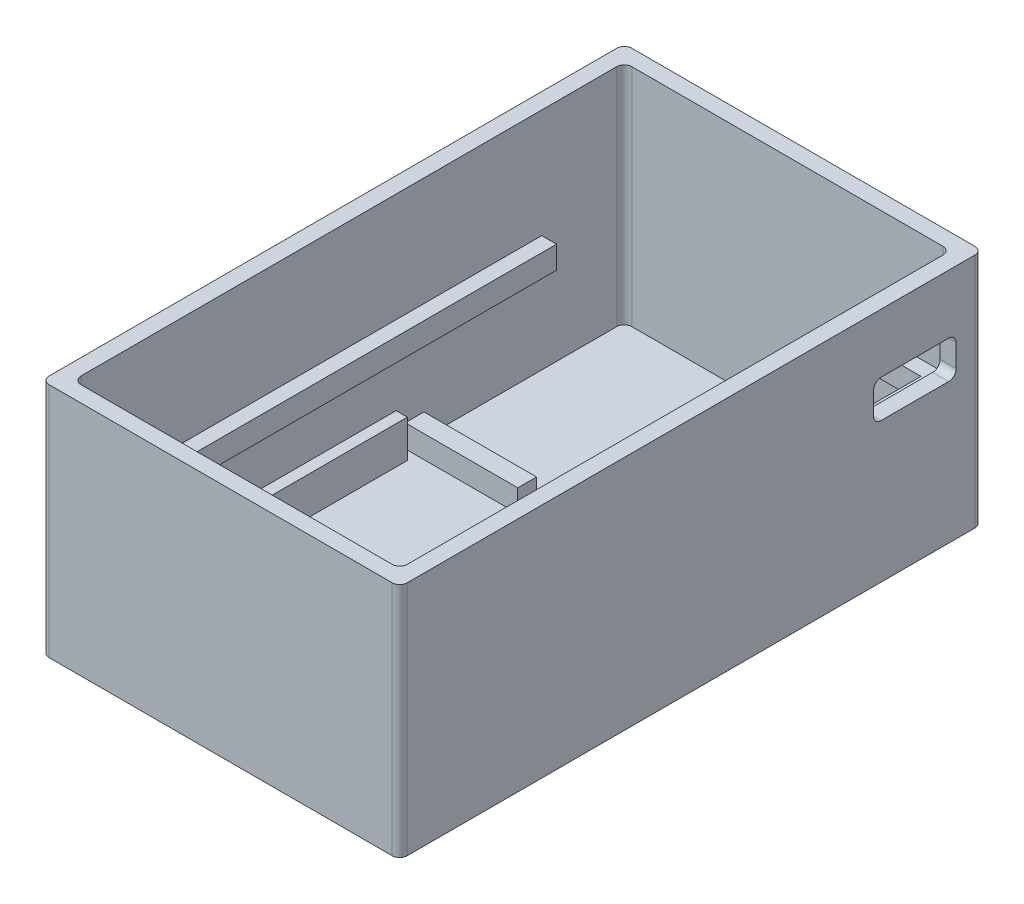
from build123d import *

# Parameters (mm, degrees)
PCB_DIMENSIONS_W    = 47.716732244
PCB_DIMENSIONS_H    = 77.636732244
BOSS_EXTRUDE3_DEPTH = 1.5
SKETCH5_W           = 47.716732244
SKETCH5_H           = 77.636732244
SKETCH5_W_2         = 43.474091557
SKETCH5_H_2         = 73.394091557
BOSS_EXTRUDE5_DEPTH = 30
FILLET1_R           = 1
SKETCH9_W           = 1.93805105
SKETCH9_H           = 42
SKETCH9_W_2         = 1.938051049
BOSS_EXTRUDE6_DEPTH = 5
SKETCH14_W          = 15
SKETCH14_H          = 2.5
BOSS_EXTRUDE7_DEPTH = 3
SKETCH15_W          = 75.636732244
SKETCH15_H          = 3
BOSS_EXTRUDE8_DEPTH = 46
SKETCH17_W          = 39.522771214
SKETCH17_H          = 62.982276128
CUT_EXTRUDE1_DEPTH  = 3
CUT_EXTRUDE2_DEPTH  = 3
SKETCH19_W          = 11
SKETCH19_H          = 5
CUT_EXTRUDE3_DEPTH  = 10
FILLET2_R           = 1
SCALE1_SCALE        = 0.99


with BuildPart() as part:
    # PCB Dimensions → Boss-Extrude3 (new body)
    with BuildSketch(Plane(origin=(0, 0, 0), x_dir=(1, 0, 0), z_dir=(0, 1, 0))):
        with Locations((20.322832216, -35.282832216)):
            Rectangle(PCB_DIMENSIONS_W, PCB_DIMENSIONS_H)
    extrude(amount=BOSS_EXTRUDE3_DEPTH)

    # Sketch5 → Boss-Extrude5 (add)
    with BuildSketch(Plane(origin=(0, 1.5, 0), x_dir=(1, 0, 0), z_dir=(0, 1, 0))):
        with Locations((20.322832216, -35.282832216)):
            Rectangle(SKETCH5_W, SKETCH5_H)
        with Locations((20.322832217, -35.282832217)):
            Rectangle(SKETCH5_W_2, SKETCH5_H_2, mode=Mode.SUBTRACT)
    extrude(amount=BOSS_EXTRUDE5_DEPTH)

    # Fillet1
    fillet1_edges = [part.edges().sort_by_distance(p)[0] for p in [
        (42.059877995, 16.5, -1.414213562),
        (-1.414213562, 16.5, -1.414213562),
        (-1.414213562, 16.5, 71.979877995),
        (42.059877995, 16.5, 71.979877995),
        (44.181198338, 15.75, 74.101198338),
        (-3.535533906, 15.75, 74.101198338),
        (-3.535533906, 15.75, -3.535533906),
        (44.181198338, 15.75, -3.535533906),
    ]]
    fillet(fillet1_edges, radius=FILLET1_R)

    # Sketch9 → Boss-Extrude6 (add)
    with BuildSketch(Plane(origin=(0, 1.5, 0), x_dir=(1, 0, 0), z_dir=(0, 1, 0))):
        with Locations((-0.88911969, -49.979881394)):
            Rectangle(SKETCH9_W, SKETCH9_H)
        with Locations((41.534784122, -49.979881394)):
            Rectangle(SKETCH9_W_2, SKETCH9_H)
    extrude(amount=BOSS_EXTRUDE6_DEPTH)

    # Sketch14 → Boss-Extrude7 (add)
    with BuildSketch(Plane(origin=(0, 1.5, 0), x_dir=(1, 0, 0), z_dir=(0, 1, 0))):
        with Locations((6.085786438, -26.529881394)):
            Rectangle(SKETCH14_W, SKETCH14_H)
        with Locations((34.559877995, -26.529881394)):
            Rectangle(SKETCH14_W, SKETCH14_H)
    extrude(amount=BOSS_EXTRUDE7_DEPTH)

    # Sketch15 → Boss-Extrude8 (add)
    with BuildSketch(Plane(origin=(44.181198338, 0, 0), x_dir=(0, 0, -1), z_dir=(1, 0, 0))):
        with Locations((-35.282832216, 15.5)):
            Rectangle(SKETCH15_W, SKETCH15_H)
    extrude(amount=-BOSS_EXTRUDE8_DEPTH)

    # Sketch17 → Cut-Extrude1 (cut)
    with BuildSketch(Plane(origin=(0, 17, 0), x_dir=(1, 0, 0), z_dir=(0, 1, 0))):
        with Locations((20.322832216, -32.052584673)):
            Rectangle(SKETCH17_W, SKETCH17_H)
    extrude(amount=-CUT_EXTRUDE1_DEPTH, mode=Mode.SUBTRACT)

    # Sketch18 → Cut-Extrude2 (cut)
    with BuildSketch(Plane(origin=(0, 17, 0), x_dir=(1, 0, 0), z_dir=(0, 1, 0))):
        with BuildLine():
            Line((-1.414213562, -9.585786438), (28.585786438, -9.585786438))
            Line((28.585786438, -9.585786438), (28.585786438, 1.414213562))
            Line((28.585786438, 1.414213562), (-0.414213562, 1.414213562))
            ThreePointArc((-0.414213562, 1.414213562), (-1.121320344, 1.121320344), (-1.414213562, 0.414213562))
            Line((-1.414213562, 0.414213562), (-1.414213562, -9.585786438))
        make_face()
    extrude(amount=-CUT_EXTRUDE2_DEPTH, mode=Mode.SUBTRACT)

    # Sketch19 → Cut-Extrude3 (cut)
    with BuildSketch(Plane(origin=(44.181198338, 0, 0), x_dir=(0, 0, -1), z_dir=(1, 0, 0))):
        with Locations((-5.464466094, 21.15)):
            Rectangle(SKETCH19_W, SKETCH19_H)
    extrude(amount=-CUT_EXTRUDE3_DEPTH, mode=Mode.SUBTRACT)

    # Fillet2
    fillet2_edges = [part.edges().sort_by_distance(p)[0] for p in [
        (43.120538167, 23.65, -0.035533906),
        (43.120538167, 18.65, -0.035533906),
        (43.120538167, 18.65, 10.964466094),
        (43.120538167, 23.65, 10.964466094),
    ]]
    fillet(fillet2_edges, radius=FILLET2_R)


with BuildPart() as part_1:
    # Scale1: scaled about (20.30907108, 12.22563111, 37.095530551)
    add(part.part.scale(SCALE1_SCALE).moved(Location((0.203090711, 0.122256311, 0.370955306))))


solid = part_1.part
